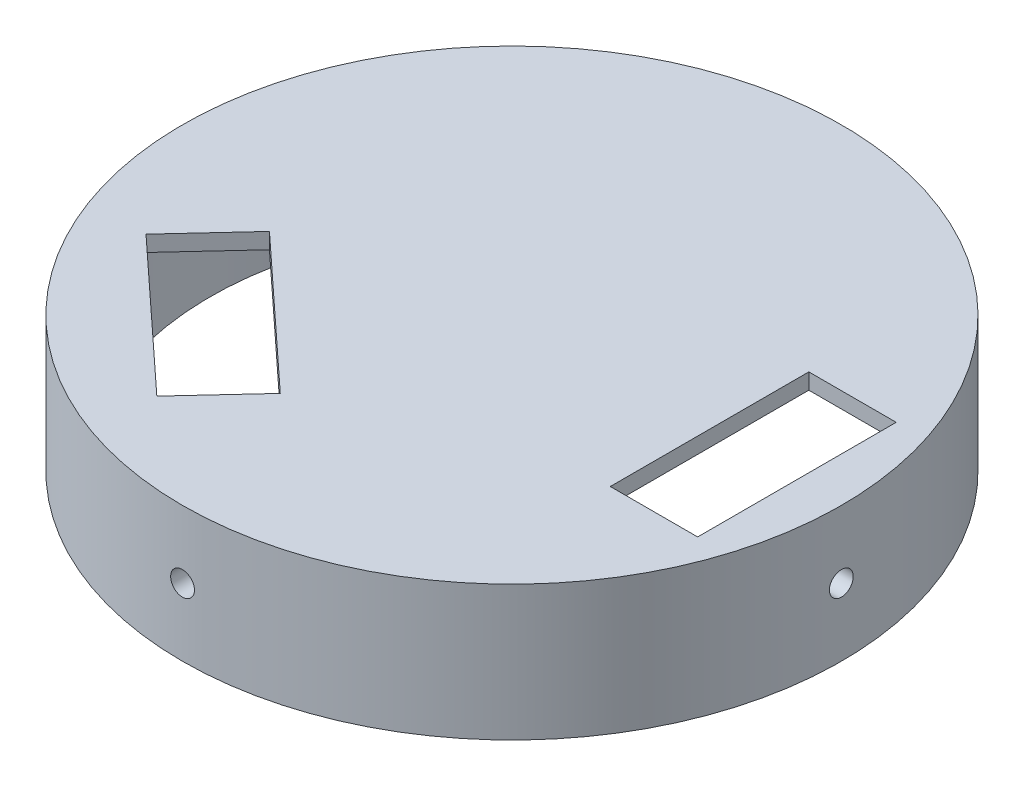
from build123d import *

# Parameters (mm, degrees)
SKETCH1_R               = 41.5
SKETCH1_R_2             = 38
BOSS_EXTRUDE1_DEPTH     = 15
SKETCH2_R               = 41.5
BOSS_EXTRUDE2_DEPTH     = 2
SKETCH3_W               = 11
SKETCH3_H               = 25
CUT_EXTRUDE1_DEPTH      = 3
SKETCH4_R               = 1.5
CUT_EXTRUDE2_DEPTH      = 80
CUT_EXTRUDE2_DEPTH_BACK = 80
SKETCH5_R               = 1.5
CUT_EXTRUDE4_DEPTH      = 80
CUT_EXTRUDE4_DEPTH_BACK = 80


with BuildPart() as part:
    # Sketch1 → Boss-Extrude1 (new body)
    with BuildSketch(Plane(origin=(0, 0, 0), x_dir=(1, 0, 0), z_dir=(0, 1, 0))):
        Circle(SKETCH1_R)
        Circle(SKETCH1_R_2, mode=Mode.SUBTRACT)
    extrude(amount=BOSS_EXTRUDE1_DEPTH)

    # Sketch2 → Boss-Extrude2 (add)
    with BuildSketch(Plane(origin=(0, 15, 0), x_dir=(1, 0, 0), z_dir=(0, 1, 0))):
        Circle(SKETCH2_R)
    extrude(amount=BOSS_EXTRUDE2_DEPTH)

    # Sketch3 → Cut-Extrude1 (cut)
    with BuildSketch(Plane(origin=(0, 17, 0), x_dir=(1, 0, 0), z_dir=(0, 1, 0))):
        Polygon((-6.046682172, -23.124314263), (-13.51904975, -31.19671928), (-31.86542479, -14.214065692), (-24.393057211, -6.141660674), align=None)
        with Locations((30.385233732, 0)):
            Rectangle(SKETCH3_W, SKETCH3_H)
    extrude(amount=-CUT_EXTRUDE1_DEPTH, mode=Mode.SUBTRACT)

    # Sketch4 → Cut-Extrude2 (cut, two sides)
    with BuildSketch(Plane.XY) as cut_extrude2_sk:
        with Locations((0, 8.5)):
            Circle(SKETCH4_R)
    extrude(amount=CUT_EXTRUDE2_DEPTH, mode=Mode.SUBTRACT)
    extrude(cut_extrude2_sk.sketch, amount=-CUT_EXTRUDE2_DEPTH_BACK, mode=Mode.SUBTRACT)

    # Sketch5 → Cut-Extrude4 (cut, two sides)
    with BuildSketch(Plane(origin=(0, 0, 0), x_dir=(0, 0, -1), z_dir=(1, 0, 0))) as cut_extrude4_sk:
        with Locations((0, 8.5)):
            Circle(SKETCH5_R)
    extrude(amount=CUT_EXTRUDE4_DEPTH, mode=Mode.SUBTRACT)
    extrude(cut_extrude4_sk.sketch, amount=-CUT_EXTRUDE4_DEPTH_BACK, mode=Mode.SUBTRACT)


solid = part.part
